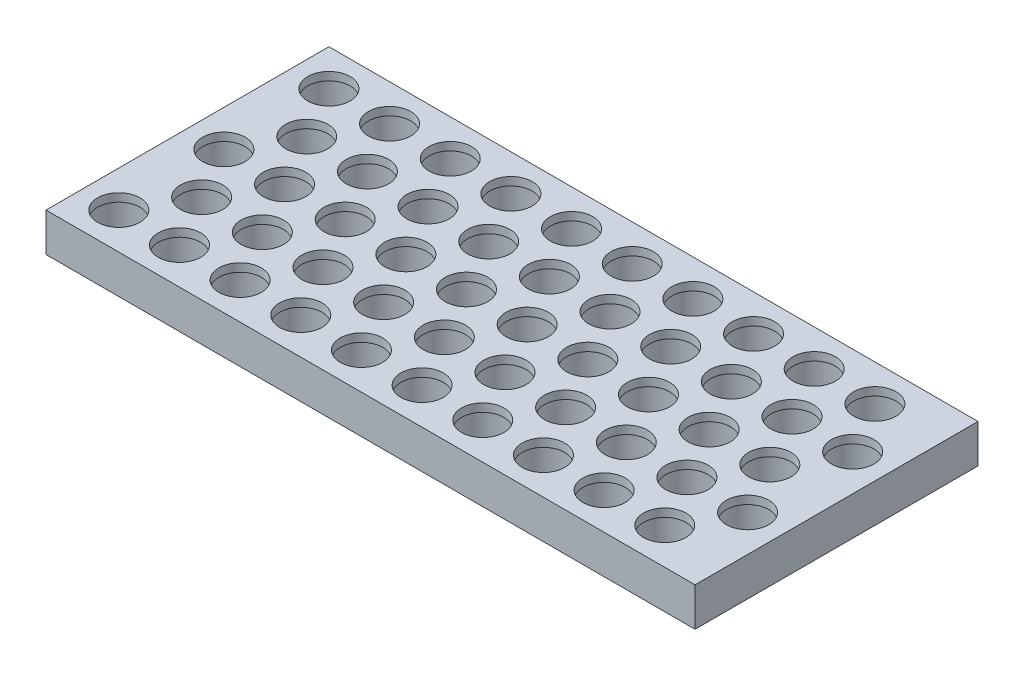
from build123d import *

# Parameters (mm, degrees)
SKETCH3_W           = 214
SKETCH3_H           = 93.282032303
BOSS_EXTRUDE1_DEPTH = 12.7
SKETCH2_R           = 9
CUT_EXTRUDE1_DEPTH  = 10
SKETCH5_R           = 7
CUT_EXTRUDE2_DEPTH  = 10


with BuildPart() as part:
    # Sketch3 → Boss-Extrude1 (new body)
    with BuildSketch(Plane(origin=(0, 0, 0), x_dir=(1, 0, 0), z_dir=(0, 1, 0))):
        with Locations((95, 34.641016152)):
            Rectangle(SKETCH3_W, SKETCH3_H)
    extrude(amount=BOSS_EXTRUDE1_DEPTH)

    # Sketch2 → Cut-Extrude1 (cut)
    with BuildSketch(Plane(origin=(0, 0, 0), x_dir=(1, 0, 0), z_dir=(0, 1, 0))):
        Circle(SKETCH2_R)
        with Locations((20, 0)):
            Circle(SKETCH2_R)
        with Locations((40, 0)):
            Circle(SKETCH2_R)
        with Locations((60, 0)):
            Circle(SKETCH2_R)
        with Locations((80, 0)):
            Circle(SKETCH2_R)
        with Locations((100, 0)):
            Circle(SKETCH2_R)
        with Locations((120, 0)):
            Circle(SKETCH2_R)
        with Locations((140, 0)):
            Circle(SKETCH2_R)
        with Locations((160, 0)):
            Circle(SKETCH2_R)
        with Locations((180, 0)):
            Circle(SKETCH2_R)
        with Locations((10, 17.320508076)):
            Circle(SKETCH2_R)
        with Locations((30, 17.320508076)):
            Circle(SKETCH2_R)
        with Locations((50, 17.320508076)):
            Circle(SKETCH2_R)
        with Locations((70, 17.320508076)):
            Circle(SKETCH2_R)
        with Locations((90, 17.320508076)):
            Circle(SKETCH2_R)
        with Locations((110, 17.320508076)):
            Circle(SKETCH2_R)
        with Locations((130, 17.320508076)):
            Circle(SKETCH2_R)
        with Locations((150, 17.320508076)):
            Circle(SKETCH2_R)
        with Locations((170, 17.320508076)):
            Circle(SKETCH2_R)
        with Locations((190, 17.320508076)):
            Circle(SKETCH2_R)
        with Locations((0, 34.641016151)):
            Circle(SKETCH2_R)
        with Locations((20, 34.641016151)):
            Circle(SKETCH2_R)
        with Locations((40, 34.641016151)):
            Circle(SKETCH2_R)
        with Locations((60, 34.641016151)):
            Circle(SKETCH2_R)
        with Locations((80, 34.641016151)):
            Circle(SKETCH2_R)
        with Locations((100, 34.641016151)):
            Circle(SKETCH2_R)
        with Locations((120, 34.641016151)):
            Circle(SKETCH2_R)
        with Locations((140, 34.641016151)):
            Circle(SKETCH2_R)
        with Locations((160, 34.641016151)):
            Circle(SKETCH2_R)
        with Locations((180, 34.641016151)):
            Circle(SKETCH2_R)
        with Locations((10, 51.961524227)):
            Circle(SKETCH2_R)
        with Locations((30, 51.961524227)):
            Circle(SKETCH2_R)
        with Locations((50, 51.961524227)):
            Circle(SKETCH2_R)
        with Locations((70, 51.961524227)):
            Circle(SKETCH2_R)
        with Locations((90, 51.961524227)):
            Circle(SKETCH2_R)
        with Locations((110, 51.961524227)):
            Circle(SKETCH2_R)
        with Locations((130, 51.961524227)):
            Circle(SKETCH2_R)
        with Locations((150, 51.961524227)):
            Circle(SKETCH2_R)
        with Locations((170, 51.961524227)):
            Circle(SKETCH2_R)
        with Locations((190, 51.961524227)):
            Circle(SKETCH2_R)
        with Locations((0, 69.282032303)):
            Circle(SKETCH2_R)
        with Locations((20, 69.282032303)):
            Circle(SKETCH2_R)
        with Locations((40, 69.282032303)):
            Circle(SKETCH2_R)
        with Locations((60, 69.282032303)):
            Circle(SKETCH2_R)
        with Locations((80, 69.282032303)):
            Circle(SKETCH2_R)
        with Locations((100, 69.282032303)):
            Circle(SKETCH2_R)
        with Locations((120, 69.282032303)):
            Circle(SKETCH2_R)
        with Locations((140, 69.282032303)):
            Circle(SKETCH2_R)
        with Locations((160, 69.282032303)):
            Circle(SKETCH2_R)
        with Locations((180, 69.282032303)):
            Circle(SKETCH2_R)
    extrude(amount=CUT_EXTRUDE1_DEPTH, mode=Mode.SUBTRACT)

    # Sketch5 → Cut-Extrude2 (cut)
    with BuildSketch(Plane.XZ.offset(-10)):
        Circle(SKETCH5_R)
        with Locations((20, 0)):
            Circle(SKETCH5_R)
        with Locations((40, 0)):
            Circle(SKETCH5_R)
        with Locations((80, 0)):
            Circle(SKETCH5_R)
        with Locations((60, 0)):
            Circle(SKETCH5_R)
        with Locations((100, 0)):
            Circle(SKETCH5_R)
        with Locations((120, 0)):
            Circle(SKETCH5_R)
        with Locations((140, 0)):
            Circle(SKETCH5_R)
        with Locations((160, 0)):
            Circle(SKETCH5_R)
        with Locations((180, 0)):
            Circle(SKETCH5_R)
        with Locations((190, -17.320508076)):
            Circle(SKETCH5_R)
        with Locations((170, -17.320508076)):
            Circle(SKETCH5_R)
        with Locations((150, -17.320508076)):
            Circle(SKETCH5_R)
        with Locations((130, -17.320508076)):
            Circle(SKETCH5_R)
        with Locations((110, -17.320508076)):
            Circle(SKETCH5_R)
        with Locations((90, -17.320508076)):
            Circle(SKETCH5_R)
        with Locations((70, -17.320508076)):
            Circle(SKETCH5_R)
        with Locations((50, -17.320508076)):
            Circle(SKETCH5_R)
        with Locations((30, -17.320508076)):
            Circle(SKETCH5_R)
        with Locations((10, -17.320508076)):
            Circle(SKETCH5_R)
        with Locations((0, -34.641016151)):
            Circle(SKETCH5_R)
        with Locations((20, -34.641016151)):
            Circle(SKETCH5_R)
        with Locations((40, -34.641016151)):
            Circle(SKETCH5_R)
        with Locations((60, -34.641016151)):
            Circle(SKETCH5_R)
        with Locations((80, -34.641016151)):
            Circle(SKETCH5_R)
        with Locations((100, -34.641016151)):
            Circle(SKETCH5_R)
        with Locations((120, -34.641016151)):
            Circle(SKETCH5_R)
        with Locations((140, -34.641016151)):
            Circle(SKETCH5_R)
        with Locations((160, -34.641016151)):
            Circle(SKETCH5_R)
        with Locations((180, -34.641016151)):
            Circle(SKETCH5_R)
        with Locations((190, -51.961524227)):
            Circle(SKETCH5_R)
        with Locations((170, -51.961524227)):
            Circle(SKETCH5_R)
        with Locations((150, -51.961524227)):
            Circle(SKETCH5_R)
        with Locations((130, -51.961524227)):
            Circle(SKETCH5_R)
        with Locations((110, -51.961524227)):
            Circle(SKETCH5_R)
        with Locations((90, -51.961524227)):
            Circle(SKETCH5_R)
        with Locations((70, -51.961524227)):
            Circle(SKETCH5_R)
        with Locations((50, -51.961524227)):
            Circle(SKETCH5_R)
        with Locations((30, -51.961524227)):
            Circle(SKETCH5_R)
        with Locations((10, -51.961524227)):
            Circle(SKETCH5_R)
        with Locations((20, -69.282032303)):
            Circle(SKETCH5_R)
        with Locations((40, -69.282032303)):
            Circle(SKETCH5_R)
        with Locations((60, -69.282032303)):
            Circle(SKETCH5_R)
        with Locations((80, -69.282032303)):
            Circle(SKETCH5_R)
        with Locations((100, -69.282032303)):
            Circle(SKETCH5_R)
        with Locations((120, -69.282032303)):
            Circle(SKETCH5_R)
        with Locations((140, -69.282032303)):
            Circle(SKETCH5_R)
        with Locations((160, -69.282032303)):
            Circle(SKETCH5_R)
        with Locations((180, -69.282032303)):
            Circle(SKETCH5_R)
        with Locations((0, -69.282032303)):
            Circle(SKETCH5_R)
    extrude(amount=-CUT_EXTRUDE2_DEPTH, mode=Mode.SUBTRACT)


solid = part.part
